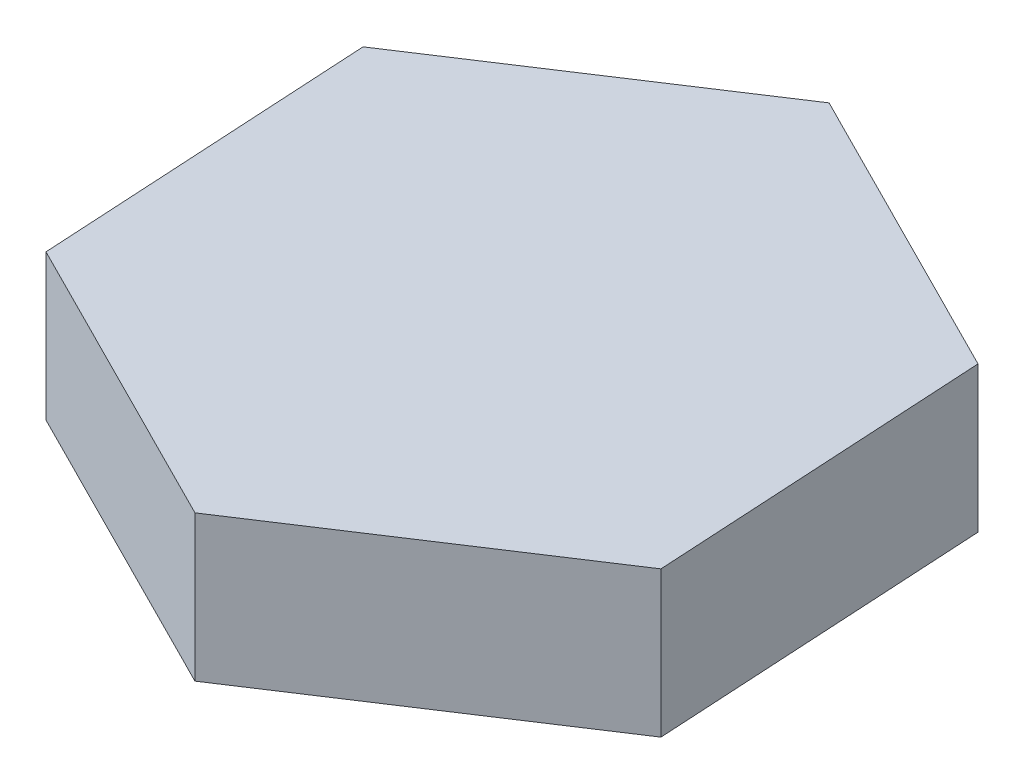
from build123d import *

# Parameters (mm, degrees)
BOSS_EXTRUDE1_DEPTH = 38.1
SKETCH2_R           = 12.7
CUT_EXTRUDE1_DEPTH  = 12.7


with BuildPart() as part:
    # Sketch1 → Boss-Extrude1 (new body)
    with BuildSketch(Plane(origin=(0, 0, 0), x_dir=(1, 0, 0), z_dir=(0, 1, 0))):
        Polygon((73.594904868, 48.225615366), (-4.967155586, 87.847864888), (-78.562060454, 39.622249522), (-73.594904868, -48.225615366), (4.967155586, -87.847864888), (78.562060454, -39.622249522), align=None)
    extrude(amount=BOSS_EXTRUDE1_DEPTH)

    # Sketch2 → Cut-Extrude1 (cut)
    with BuildSketch(Plane.XZ):
        Circle(SKETCH2_R)
    extrude(amount=-CUT_EXTRUDE1_DEPTH, mode=Mode.SUBTRACT)


solid = part.part
